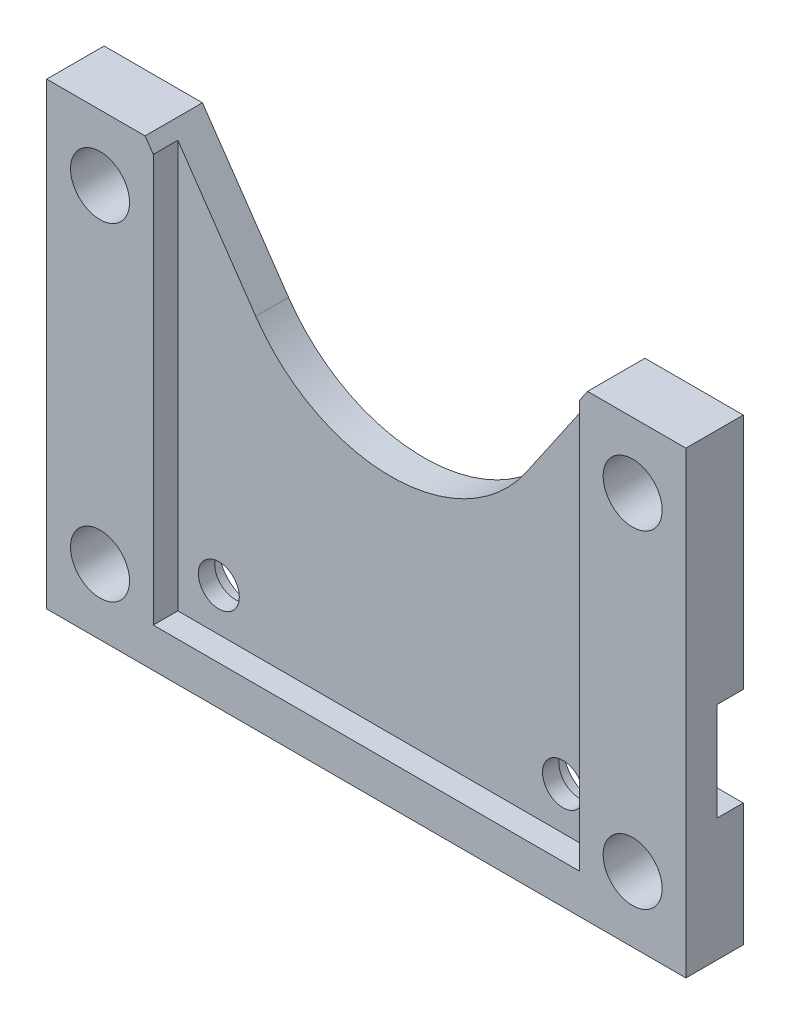
from build123d import *

# Parameters (mm, degrees)
SKETCH_1_R          = 1.25
SKETCH_1_R_2        = 1.8
EXTRUDE_1_DEPTH     = 2
SKETCH_3_R          = 1.8
EXTRUDE_2_DEPTH     = 1.5
SKETCH_4_R          = 2
CUT_EXTRUDE_1_DEPTH = 1
SKETCH_5_W          = 1.6
SKETCH_5_H          = 6
CUT_EXTRUDE_6_DEPTH = 40


with BuildPart() as part:
    # ｽｹｯﾁ1 → ﾎﾞｽ - 押し出し1 (new body)
    with BuildSketch(Plane.XY):
        with BuildLine():
            Line((19.5, -5), (-19.5, -5))
            Line((-19.5, -5), (-19.5, 23))
            Line((-19.5, 23), (-13.5, 23))
            Line((-13.5, 23), (-8.245593322, 15.342245077))
            ThreePointArc((-8.245593322, 15.342245077), (0, 11), (8.245593322, 15.342245077))
            Line((8.245593322, 15.342245077), (13.5, 23))
            Line((13.5, 23), (19.5, 23))
            Line((19.5, 23), (19.5, -5))
        make_face()
        with Locations((-10.5, 0)):
            Circle(SKETCH_1_R, mode=Mode.SUBTRACT)
        with Locations((10.5, 0)):
            Circle(SKETCH_1_R, mode=Mode.SUBTRACT)
        with Locations((-16.25, -1)):
            Circle(SKETCH_1_R_2, mode=Mode.SUBTRACT)
        with Locations((-16.25, 19)):
            Circle(SKETCH_1_R_2, mode=Mode.SUBTRACT)
        with Locations((16.25, -1)):
            Circle(SKETCH_1_R_2, mode=Mode.SUBTRACT)
        with Locations((16.25, 19)):
            Circle(SKETCH_1_R_2, mode=Mode.SUBTRACT)
    extrude(amount=EXTRUDE_1_DEPTH)

    # ｽｹｯﾁ3 → ﾎﾞｽ - 押し出し2 (add)
    with BuildSketch(Plane.XY.offset(2)):
        Polygon((-13, 22.271301653), (-13, -2.6), (13, -2.6), (13, 22.271301653), (13.5, 23), (19.5, 23), (19.5, -5), (-19.5, -5), (-19.5, 23), (-13.5, 23), align=None)
        with Locations((-16.25, 19)):
            Circle(SKETCH_3_R, mode=Mode.SUBTRACT)
        with Locations((-16.25, -1)):
            Circle(SKETCH_3_R, mode=Mode.SUBTRACT)
        with Locations((16.25, -1)):
            Circle(SKETCH_3_R, mode=Mode.SUBTRACT)
        with Locations((16.25, 19)):
            Circle(SKETCH_3_R, mode=Mode.SUBTRACT)
    extrude(amount=EXTRUDE_2_DEPTH)

    # ｽｹｯﾁ4 → ｶｯﾄ - 押し出し1 (cut)
    with BuildSketch(Plane(origin=(0, 0, 0), x_dir=(-1, 0, 0), z_dir=(0, 0, -1))):
        with Locations((-10.5, 0)):
            Circle(SKETCH_4_R)
        with Locations((10.5, 0)):
            Circle(SKETCH_4_R)
    extrude(amount=-CUT_EXTRUDE_1_DEPTH, mode=Mode.SUBTRACT)

    # ｽｹｯﾁ5 → ｶｯﾄ - 押し出し6 (cut, through all)
    with BuildSketch(Plane.ZY.offset(19.5)):
        with Locations((0.8, 5.5)):
            Rectangle(SKETCH_5_W, SKETCH_5_H)
    extrude(amount=-CUT_EXTRUDE_6_DEPTH, mode=Mode.SUBTRACT)


solid = part.part
